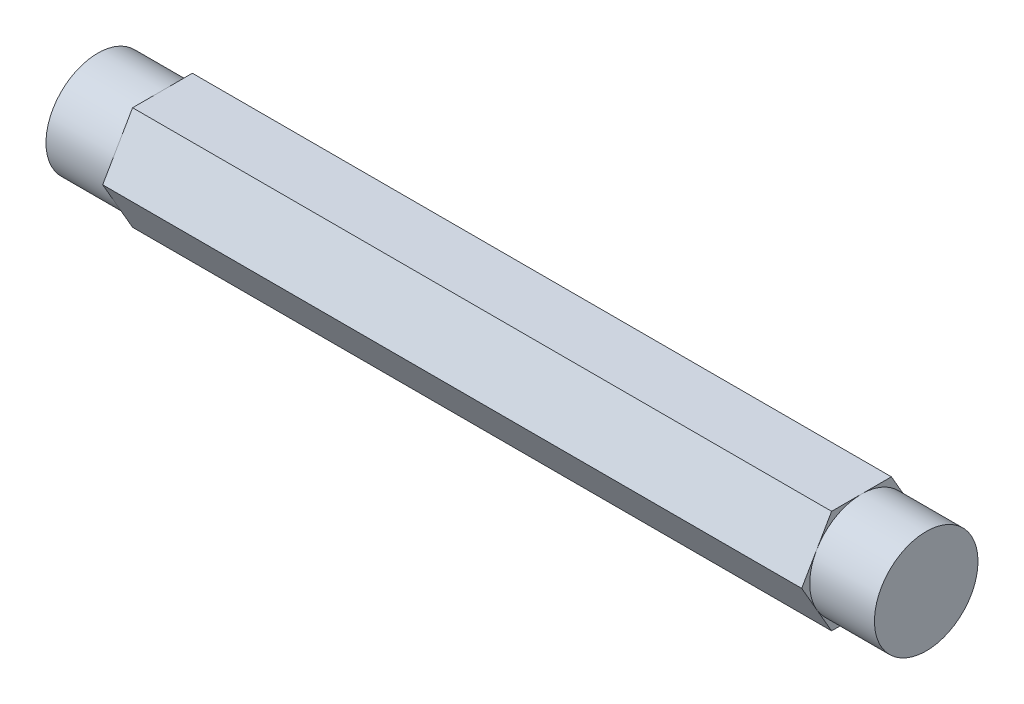
from build123d import *

# Parameters (mm, degrees)
BOSS_EXTRUDE1_DEPTH     = 50.8
SKETCH3_R               = 8.89
SKETCH3_R_2             = 6.35
CUT_EXTRUDE_THIN1_DEPTH = 7.9375


with BuildPart() as part:
    # Sketch2 → Boss-Extrude1 (new body, symmetric)
    with BuildSketch(Plane(origin=(0, 0, 0), x_dir=(0, 0, -1), z_dir=(1, 0, 0))):
        Polygon((7.332348419, 0), (3.666174209, 6.35), (-3.666174209, 6.35), (-7.332348419, 0), (-3.666174209, -6.35), (3.666174209, -6.35), align=None)
    extrude(amount=BOSS_EXTRUDE1_DEPTH, both=True)

    # Sketch3 → Cut-Extrude-Thin1 (cut)
    with BuildSketch(Plane(origin=(50.8, 0, 0), x_dir=(0, 0, -1), z_dir=(1, 0, 0))):
        Circle(SKETCH3_R)
        Circle(SKETCH3_R_2, mode=Mode.SUBTRACT)
    cut_extrude_thin1 = extrude(amount=-CUT_EXTRUDE_THIN1_DEPTH, mode=Mode.SUBTRACT)

    # Mirror1: Cut-Extrude-Thin1 across plane
    add(cut_extrude_thin1.mirror(Plane(origin=(0, 0, 0), x_dir=(0, 0, 1), z_dir=(1, 0, 0))), mode=Mode.SUBTRACT)


solid = part.part
